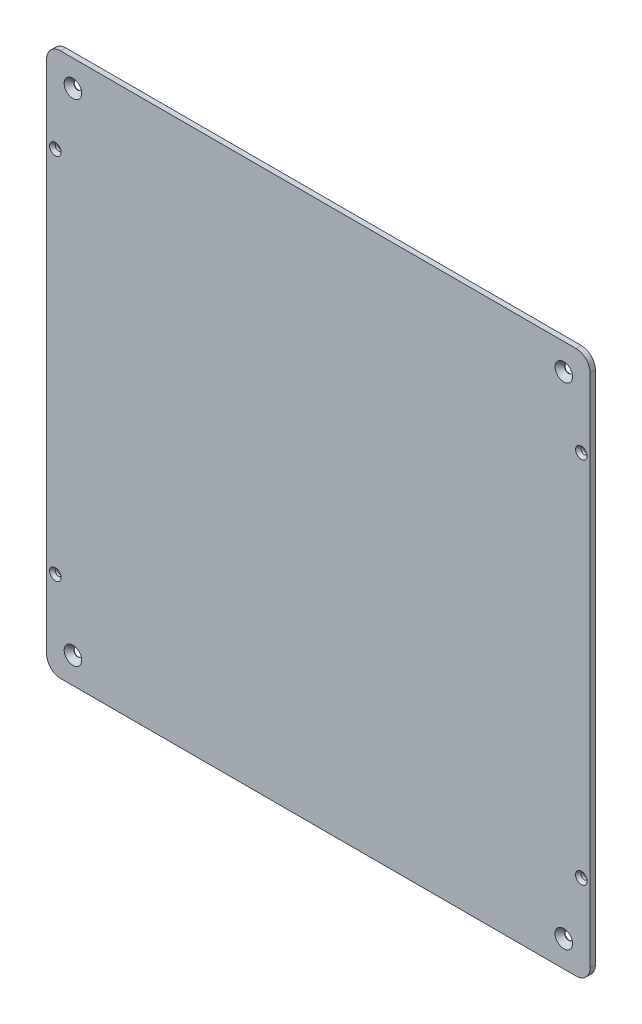
from build123d import *

# Parameters (mm, degrees)
EXTRUDE_1_DEPTH             = 3
HOLE_WIZARD_1_AT_2_COUNT    = 2
HOLE_WIZARD_1_AT_2_PITCH    = 280
HOLE_WIZARD_1_AT_3_COUNT    = 2
HOLE_WIZARD_1_AT_3_PITCH    = 395.979797464
HOLE_WIZARD_1_AT_4_COUNT    = 2
HOLE_WIZARD_1_AT_4_PITCH    = 280
SKETCH_4_W                  = 8
SKETCH_4_H                  = 15
EXTRUDE_2_DEPTH             = 1
HOLE_WIZARD_1_2_D           = 3.4
HOLE_WIZARD_1_2_CSINK_D     = 6.6
HOLE_WIZARD_1_2_CSINK_ANGLE = 90


with BuildPart() as part:
    # 草图1 → 凸台-拉伸1 (new body)
    with BuildSketch(Plane.XY):
        with BuildLine():
            Line((-147, 155), (147, 155))
            ThreePointArc((147, 155), (152.656854249, 152.656854249), (155, 147))
            Line((155, 147), (155, -147))
            ThreePointArc((155, -147), (152.656854249, -152.656854249), (147, -155))
            Line((147, -155), (-147, -155))
            ThreePointArc((-147, -155), (-152.656854249, -152.656854249), (-155, -147))
            Line((-155, -147), (-155, 147))
            ThreePointArc((-155, 147), (-152.656854249, 152.656854249), (-147, 155))
        make_face()
    extrude(amount=EXTRUDE_1_DEPTH)

    # 草图2 → Hole Wizard 1 (revolve, cut)
    with BuildSketch(Plane(origin=(-140, 140, 3), x_dir=(0, -1, 0), z_dir=(1, 0, 0))):
        Polygon((0, 0), (0, 3), (2.25, 3), (2.25, 2.75), (5, 0), align=None)
    hole_wizard_1 = revolve(axis=Axis((-140, 140, 9.35), (0, 0, -1)), mode=Mode.SUBTRACT)

    # Hole Wizard 1 at 2: Hole Wizard 1 ×2
    with Locations(*[(i * HOLE_WIZARD_1_AT_2_PITCH, 0, 0) for i in range(1, HOLE_WIZARD_1_AT_2_COUNT)]):
        add(hole_wizard_1, mode=Mode.SUBTRACT)

    # Hole Wizard 1 at 3: Hole Wizard 1 ×2
    with Locations(*[Vector(0.707106781, -0.707106781, 0) * (i * HOLE_WIZARD_1_AT_3_PITCH) for i in range(1, HOLE_WIZARD_1_AT_3_COUNT)]):
        add(hole_wizard_1, mode=Mode.SUBTRACT)

    # Hole Wizard 1 at 4: Hole Wizard 1 ×2
    with Locations(*[(0, -i * HOLE_WIZARD_1_AT_4_PITCH, 0) for i in range(1, HOLE_WIZARD_1_AT_4_COUNT)]):
        add(hole_wizard_1, mode=Mode.SUBTRACT)

    # 草图4 → 凸台-拉伸2 (add)
    with BuildSketch(Plane(origin=(0, 0, 0), x_dir=(-1, 0, 0), z_dir=(0, 0, -1))):
        with Locations((-19, 111.5)):
            Rectangle(SKETCH_4_W, SKETCH_4_H)
        with Locations((-33, 111.5)):
            Rectangle(SKETCH_4_W, SKETCH_4_H)
    extrude(amount=EXTRUDE_2_DEPTH)

    # Hole Wizard 1 2 (through all)
    with Locations(Plane.XY.offset(3)):
        with Locations((150, -105), (150, 105), (-150, 105), (-150, -105)):
            CounterSinkHole(HOLE_WIZARD_1_2_D / 2, HOLE_WIZARD_1_2_CSINK_D / 2, counter_sink_angle=HOLE_WIZARD_1_2_CSINK_ANGLE)


solid = part.part
